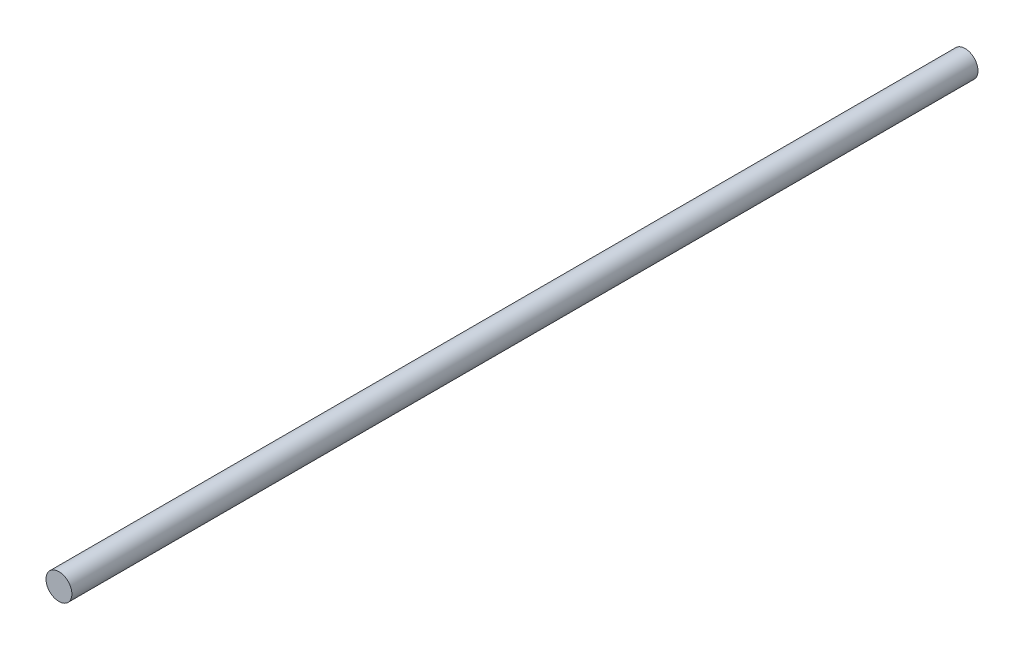
from build123d import *

# Parameters (mm, degrees)
CROQUIS1_R              = 4
SALIENTE_EXTRUIR1_DEPTH = 280


with BuildPart() as part:
    # Croquis1 → Saliente-Extruir1 (new body)
    with BuildSketch(Plane.XY):
        Circle(CROQUIS1_R)
    extrude(amount=SALIENTE_EXTRUIR1_DEPTH)


solid = part.part
